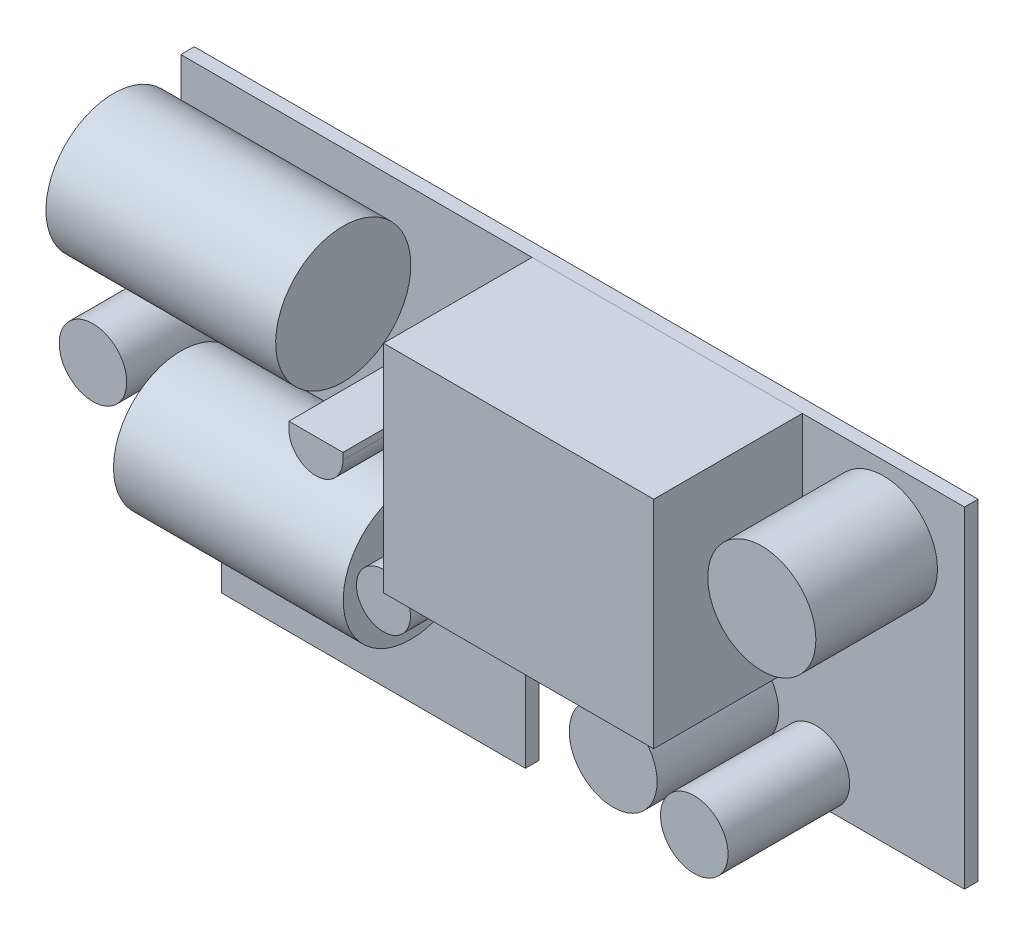
from build123d import *

# Parameters (mm, degrees)
ESBO_O1_W                  = 58
ESBO_O1_H                  = 33
RESSALTO_EXTRUS_O1_DEPTH   = 1
ESBO_O2_W                  = 3
ESBO_O2_H                  = 8.5
ESBO_O2_W_2                = 32.5
CORTE_EXTRUS_O1_DEPTH      = 2
ESBO_O3_W                  = 20
ESBO_O3_H                  = 16
RESSALTO_EXTRUS_O2_DEPTH   = 11
ESBO_O4_R                  = 3.25
RESSALTO_EXTRUS_O3_DEPTH   = 9
ESBO_O4_R_2                = 2.5
RESSALTO_EXTRUS_O3_2_DEPTH = 9
ESBO_O4_R_3                = 4
RESSALTO_EXTRUS_O3_3_DEPTH = 9
RESSALTO_EXTRUS_O3_4_DEPTH = 9
ESBO_O4_R_4                = 2
RESSALTO_EXTRUS_O3_5_DEPTH = 9
RESSALTO_EXTRUS_O3_6_DEPTH = 9
ESBO_O5_R                  = 5
RESSALTO_EXTRUS_O4_DEPTH   = 17
RESSALTO_EXTRUS_O5_START   = -5
ESBO_O6_R                  = 5
RESSALTO_EXTRUS_O5_DEPTH   = 17


with BuildPart() as part:
    # Esboço1 → Ressalto-extrusão1 (new body)
    with BuildSketch(Plane.XY):
        Rectangle(ESBO_O1_W, ESBO_O1_H)
    extrude(amount=RESSALTO_EXTRUS_O1_DEPTH)

    # Esboço2 → Corte-extrusão1 (cut, through all)
    with BuildSketch(Plane.XY.offset(1)):
        with Locations((-27.5, -12.25)):
            Rectangle(ESBO_O2_W, ESBO_O2_H)
        with Locations((12.75, -12.25)):
            Rectangle(ESBO_O2_W_2, ESBO_O2_H)
    extrude(amount=-CORTE_EXTRUS_O1_DEPTH, mode=Mode.SUBTRACT)


with BuildPart() as body_2:
    # Esboço3 → Ressalto-extrusão2 (new body)
    with BuildSketch(Plane.XY.offset(1)):
        with Locations((7, 8.5)):
            Rectangle(ESBO_O3_W, ESBO_O3_H)
    extrude(amount=RESSALTO_EXTRUS_O2_DEPTH)


with BuildPart() as body_3:
    # Esboço4 → Ressalto-extrusão3 (new body)
    with BuildSketch(Plane.XY.offset(1)):
        with Locations((12, -3.5)):
            Circle(ESBO_O4_R)
    extrude(amount=RESSALTO_EXTRUS_O3_DEPTH)


with BuildPart() as body_4:
    # Esboço4 → Ressalto-extrus_o3 2 (new body)
    with BuildSketch(Plane.XY.offset(1)):
        with Locations((18, -5.5)):
            Circle(ESBO_O4_R_2)
    extrude(amount=RESSALTO_EXTRUS_O3_2_DEPTH)


with BuildPart() as body_5:
    # Esboço4 → Ressalto-extrus_o3 3 (new body)
    with BuildSketch(Plane.XY.offset(1)):
        with Locations((23, 11.5)):
            Circle(ESBO_O4_R_3)
    extrude(amount=RESSALTO_EXTRUS_O3_3_DEPTH)


with BuildPart() as body_6:
    # Esboço4 → Ressalto-extrus_o3 4 (new body)
    with BuildSketch(Plane.XY.offset(1)):
        with Locations((-26.5, 2.5)):
            Circle(ESBO_O4_R_2)
    extrude(amount=RESSALTO_EXTRUS_O3_4_DEPTH)


with BuildPart() as body_7:
    # Esboço4 → Ressalto-extrus_o3 5 (new body)
    with BuildSketch(Plane.XY.offset(1)):
        with Locations((-5, -2)):
            Circle(ESBO_O4_R_4)
    extrude(amount=RESSALTO_EXTRUS_O3_5_DEPTH)


with BuildPart() as body_8:
    # Esboço4 → Ressalto-extrus_o3 6 (new body)
    with BuildSketch(Plane.XY.offset(1)):
        with BuildLine():
            Line((-12, 6), (-8, 6))
            Line((-8, 6), (-8, 5.5))
            ThreePointArc((-8, 5.5), (-10, 3.5), (-12, 5.5))
            Line((-12, 5.5), (-12, 6))
        make_face()
    extrude(amount=RESSALTO_EXTRUS_O3_6_DEPTH)


with BuildPart() as body_9:
    # Esboço5 → Ressalto-extrusão4 (new body)
    with BuildSketch(Plane.ZY.offset(29)):
        with Locations((5.978654941, 11.5)):
            Circle(ESBO_O5_R)
    extrude(amount=-RESSALTO_EXTRUS_O4_DEPTH)


with BuildPart() as body_10:
    # Esboço6 → Ressalto-extrusão5 (new body)
    with BuildSketch(Plane.ZY.offset(29).offset(RESSALTO_EXTRUS_O5_START)):
        with Locations((5.978654941, -2.5)):
            Circle(ESBO_O6_R)
    extrude(amount=-RESSALTO_EXTRUS_O5_DEPTH)


solid = Compound([part.part, body_2.part, body_3.part, body_4.part, body_5.part, body_6.part, body_7.part, body_8.part, body_9.part, body_10.part])
